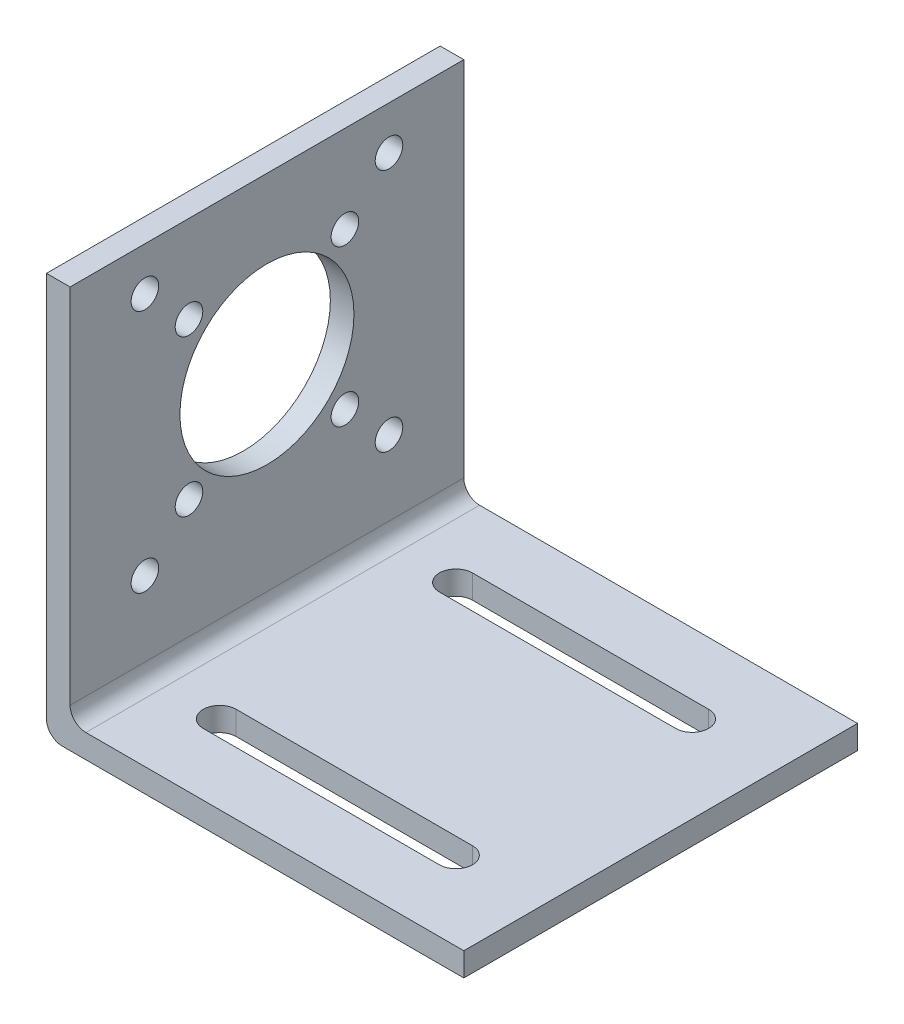
from build123d import *

# Parameters (mm, degrees)
SKETCH1_W           = 53
SKETCH1_H           = 50
BOSS_EXTRUDE1_DEPTH = 3
SKETCH2_W           = 3
SKETCH2_H           = 50
BOSS_EXTRUDE2_DEPTH = 48
CUT_EXTRUDE1_DEPTH  = 4
FILLET1_R           = 2
SKETCH4_R           = 1.75
SKETCH4_R_2         = 11.05
CUT_EXTRUDE2_DEPTH  = 4


with BuildPart() as part:
    # Sketch1 → Boss-Extrude1 (new body)
    with BuildSketch(Plane(origin=(0, 0, 0), x_dir=(1, 0, 0), z_dir=(0, 1, 0))):
        with Locations((26.5, 25)):
            Rectangle(SKETCH1_W, SKETCH1_H)
    extrude(amount=BOSS_EXTRUDE1_DEPTH)

    # Sketch2 → Boss-Extrude2 (add)
    with BuildSketch(Plane(origin=(0, 3, 0), x_dir=(1, 0, 0), z_dir=(0, 1, 0))):
        with Locations((1.5, 25)):
            Rectangle(SKETCH2_W, SKETCH2_H)
    extrude(amount=BOSS_EXTRUDE2_DEPTH)

    # Sketch3 → Cut-Extrude1 (cut, through all)
    with BuildSketch(Plane(origin=(0, 3, 0), x_dir=(1, 0, 0), z_dir=(0, 1, 0))):
        with BuildLine():
            Line((12, 37.9), (42, 37.9))
            ThreePointArc((42, 37.9), (44.1, 40), (42, 42.1))
            Line((42, 42.1), (12, 42.1))
            ThreePointArc((12, 42.1), (9.9, 40), (12, 37.9))
        make_face()
        with BuildLine():
            ThreePointArc((42, 12.1), (44.1, 10), (42, 7.9))
            Line((42, 7.9), (12, 7.9))
            ThreePointArc((12, 7.9), (9.9, 10), (12, 12.1))
            Line((12, 12.1), (42, 12.1))
        make_face()
    extrude(amount=-CUT_EXTRUDE1_DEPTH, mode=Mode.SUBTRACT)

    # Fillet1
    fillet1_edges = [part.edges().sort_by_distance(p)[0] for p in [
        (3, 3, -25),
        (0, 0, -25),
    ]]
    fillet(fillet1_edges, radius=FILLET1_R)

    # Sketch4 → Cut-Extrude2 (cut, through all)
    with BuildSketch(Plane(origin=(3, 0, 0), x_dir=(0, 0, -1), z_dir=(1, 0, 0))):
        with Locations((9.5, 45.5)):
            Circle(SKETCH4_R)
        with Locations((15.101010153, 39.9)):
            Circle(SKETCH4_R)
        with Locations((25, 30)):
            Circle(SKETCH4_R_2)
        with Locations((15.101010153, 20.1)):
            Circle(SKETCH4_R)
        with Locations((9.5, 14.5)):
            Circle(SKETCH4_R)
        with Locations((34.898989847, 20.1)):
            Circle(SKETCH4_R)
        with Locations((40.5, 14.5)):
            Circle(SKETCH4_R)
        with Locations((34.898989847, 39.9)):
            Circle(SKETCH4_R)
        with Locations((40.5, 45.5)):
            Circle(SKETCH4_R)
    extrude(amount=-CUT_EXTRUDE2_DEPTH, mode=Mode.SUBTRACT)


solid = part.part
